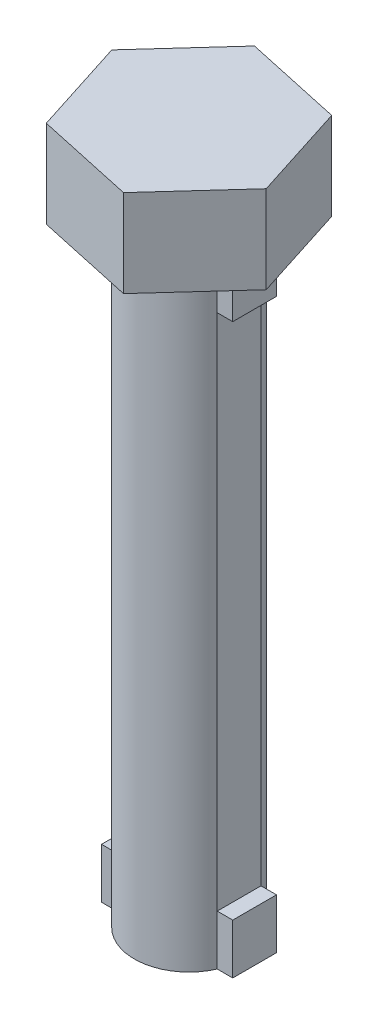
from build123d import *

# Parameters (mm, degrees)
BOSS_EXTRUDE1_DEPTH     = 14
BOSS_EXTRUDE2_DEPTH     = 2
SKETCH3_W               = 0.354356076
SKETCH3_H               = 11.846889002
CUT_EXTRUDE1_DEPTH      = 3.199876682
CUT_EXTRUDE1_DEPTH_BACK = 3.199876682


with BuildPart() as part:
    # Sketch1 → Boss-Extrude1 (new body)
    with BuildSketch(Plane(origin=(0, 0, 0), x_dir=(1, 0, 0), z_dir=(0, 1, 0))):
        with BuildLine():
            Line((-1.145643924, 0.5), (-1.5, 0.5))
            Line((-1.5, 0.5), (-1.5, -0.5))
            Line((-1.5, -0.5), (-1.145643924, -0.5))
            ThreePointArc((-1.145643924, -0.5), (0, -1.25), (1.145643924, -0.5))
            Line((1.145643924, -0.5), (1.5, -0.5))
            Line((1.5, -0.5), (1.5, 0.5))
            Line((1.5, 0.5), (1.145643924, 0.5))
            ThreePointArc((1.145643924, 0.5), (0, 1.25), (-1.145643924, 0.5))
        make_face()
    extrude(amount=BOSS_EXTRUDE1_DEPTH)

    # Sketch2 → Boss-Extrude2 (add)
    with BuildSketch(Plane(origin=(0, 14, 0), x_dir=(1, 0, 0), z_dir=(0, 1, 0))):
        Polygon((-1.553767561, -1.708549004), (0.702763061, -2.199876682), (2.256530622, -0.491327678), (1.553767561, 1.708549004), (-0.702763061, 2.199876682), (-2.256530622, 0.491327678), align=None)
    extrude(amount=BOSS_EXTRUDE2_DEPTH)

    # Sketch3 → Cut-Extrude1 (cut, two sides)
    with BuildSketch(Plane.XY) as cut_extrude1_sk:
        with Locations((1.322821962, 7.070449387)):
            Rectangle(SKETCH3_W, SKETCH3_H)
        with Locations((-1.322821962, 7.070449387)):
            Rectangle(SKETCH3_W, SKETCH3_H)
    extrude(amount=CUT_EXTRUDE1_DEPTH, mode=Mode.SUBTRACT)
    extrude(cut_extrude1_sk.sketch, amount=-CUT_EXTRUDE1_DEPTH_BACK, mode=Mode.SUBTRACT)


solid = part.part
